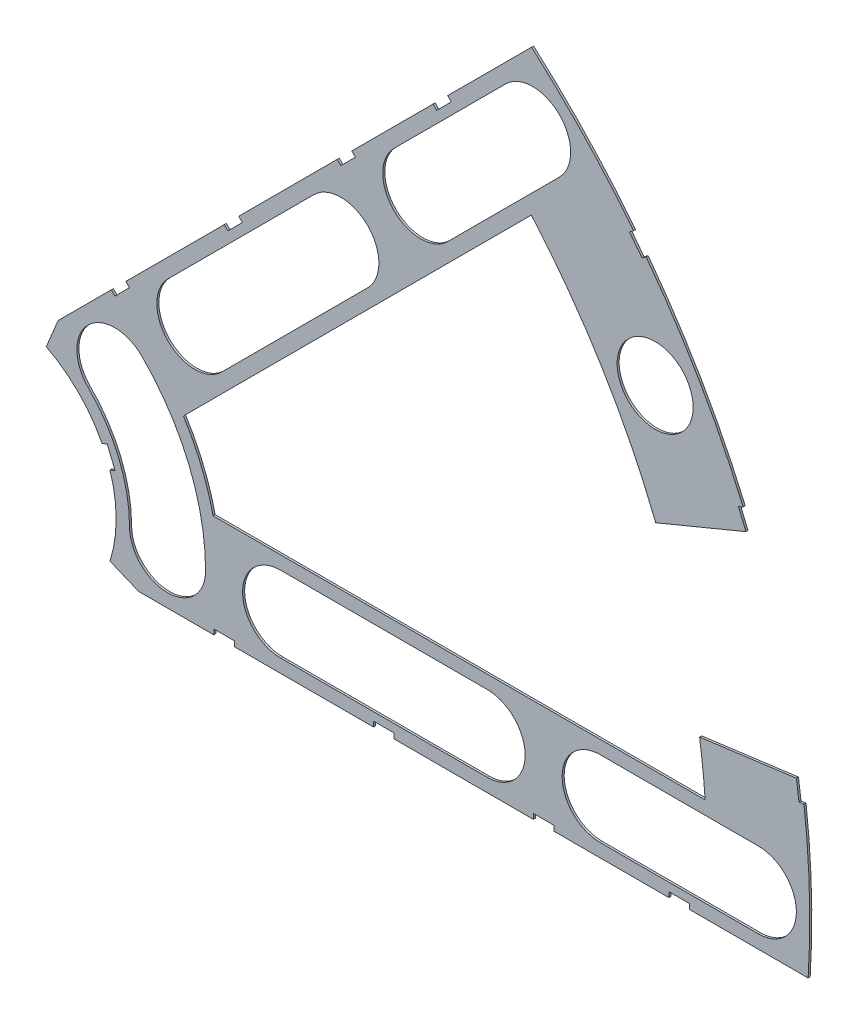
from build123d import *

# Parameters (mm, degrees)
BOSS_EXTRUDE1_DEPTH = 0.254
SKETCH2_R           = 4.699
CUT_EXTRUDE1_DEPTH  = 1.254
SKETCH3_W           = 2.54
SKETCH3_H           = 0.635
CUT_EXTRUDE2_DEPTH  = 1.254
CUT_EXTRUDE4_DEPTH  = 1.254
CUT_EXTRUDE5_DEPTH  = 1.254


with BuildPart() as part:
    # Sketch1 → Boss-Extrude1 (new body)
    with BuildSketch(Plane.XY):
        with BuildLine():
            Line((67.21146711, 76.191723231), (8.696654013, 17.676910134))
            Line((8.696654013, 17.676910134), (7.228954972, 14.133571205))
            ThreePointArc((7.228954972, 14.133571205), (14.666587579, 6.075099489), (15.105587123, -4.88230096))
            Line((15.105587123, -4.88230096), (18.648926052, -6.35))
            Line((18.648926052, -6.35), (101.401368334, -6.35))
            ThreePointArc((101.401368334, -6.35), (93.866160503, 38.880636728), (67.21146711, 76.191723231))
        make_face()
        with BuildLine():
            Line((88.672924278, 6.35), (27.86051193, 6.35))
            ThreePointArc((27.86051193, 6.35), (26.399857642, 10.93517908), (24.190484974, 15.210228852))
            Line((24.190484974, 15.210228852), (67.191354125, 58.211098004))
            ThreePointArc((67.191354125, 58.211098004), (82.13289044, 34.020557137), (88.672924278, 6.35))
        make_face(mode=Mode.SUBTRACT)
    extrude(amount=BOSS_EXTRUDE1_DEPTH)

    # Sketch2 → Cut-Extrude1 (cut, through all)
    with BuildSketch(Plane.XY.offset(0.254)):
        with Locations((22.225, 0)):
            Circle(SKETCH2_R)
        with Locations((36.195, 0)):
            Circle(SKETCH2_R)
        with Locations((61.722, 0)):
            Circle(SKETCH2_R)
        with Locations((75.692, 0)):
            Circle(SKETCH2_R)
        with Locations((95.25, 0)):
            Circle(SKETCH2_R)
        with Locations((15.715448212, 15.715448212)):
            Circle(SKETCH2_R)
        with Locations((25.593729945, 25.593729945)):
            Circle(SKETCH2_R)
        with Locations((43.644044748, 43.644044748)):
            Circle(SKETCH2_R)
        with Locations((53.522326482, 53.522326482)):
            Circle(SKETCH2_R)
        with Locations((92.004434954, 24.652514046)):
            Circle(SKETCH2_R)
        with Locations((82.48891971, 47.625)):
            Circle(SKETCH2_R)
        with Locations((67.351920908, 67.351920908)):
            Circle(SKETCH2_R)
    extrude(amount=-CUT_EXTRUDE1_DEPTH, mode=Mode.SUBTRACT)

    # Sketch3 → Cut-Extrude2 (cut, through all)
    with BuildSketch(Plane.XY.offset(0.254)):
        Polygon((15.266435406, 24.246691527), (17.06248663, 26.042742751), (17.511499436, 25.593729945), (15.715448212, 23.797678721), align=None)
        Polygon((44.991083167, 53.971339288), (43.195031942, 52.175288063), (43.644044748, 51.726275257), (45.440095973, 53.522326482), align=None)
        with Locations((29.21, -6.0325)):
            Rectangle(SKETCH3_W, SKETCH3_H)
        with Locations((68.707, -6.0325)):
            Rectangle(SKETCH3_W, SKETCH3_H)
        Polygon((29.230733674, 38.210989795), (31.026784898, 40.007041019), (31.475797704, 39.558028213), (29.67974648, 37.761976989), align=None)
        Polygon((56.845021246, 65.825277367), (55.048970022, 64.029226143), (55.497982828, 63.580213337), (57.294034052, 65.376264561), align=None)
        with Locations((48.9585, -6.0325)):
            Rectangle(SKETCH3_W, SKETCH3_H)
        with Locations((85.471, -6.0325)):
            Rectangle(SKETCH3_W, SKETCH3_H)
        Polygon((99.935462164, 14.437711971), (100.266998693, 11.919442024), (101.526133667, 12.085210288), (101.194597138, 14.603480236), align=None)
        Polygon((93.765504959, 37.464305742), (94.938831965, 37.950313702), (93.966816047, 40.296967714), (92.793489041, 39.810959755), align=None)
        Polygon((79.327792988, 62.471156422), (80.874047017, 60.456038938), (81.88160576, 61.229165953), (80.33535173, 63.244283437), align=None)
        Polygon((13.593916116, 7.005422516), (14.565932035, 4.658768503), (15.739259041, 5.144776462), (14.767243123, 7.491430475), align=None)
    extrude(amount=-CUT_EXTRUDE2_DEPTH, mode=Mode.SUBTRACT)

    # Sketch6 → Cut-Extrude4 (cut, through all)
    with BuildSketch(Plane.XY.offset(0.254)):
        with BuildLine():
            Line((22.27103518, 28.91642471), (40.321349984, 46.966739513))
            ThreePointArc((40.321349984, 46.966739513), (46.966739513, 46.966739513), (46.966739513, 40.321349984))
            Line((46.966739513, 40.321349984), (28.91642471, 22.27103518))
            ThreePointArc((28.91642471, 22.27103518), (22.27103518, 22.27103518), (22.27103518, 28.91642471))
        make_face()
        with BuildLine():
            Line((50.199631717, 56.845021246), (64.029226143, 70.674615673))
            ThreePointArc((64.029226143, 70.674615673), (70.674615673, 70.674615673), (70.674615673, 64.029226143))
            Line((70.674615673, 64.029226143), (56.845021246, 50.199631717))
            ThreePointArc((56.845021246, 50.199631717), (50.199631717, 50.199631717), (50.199631717, 56.845021246))
        make_face()
        with BuildLine():
            Line((61.722, -4.699), (36.195, -4.699))
            ThreePointArc((36.195, -4.699), (31.496, 0), (36.195, 4.699))
            Line((36.195, 4.699), (61.722, 4.699))
            ThreePointArc((61.722, 4.699), (66.421, 0), (61.722, -4.699))
        make_face()
        with BuildLine():
            Line((95.25, -4.699), (75.692, -4.699))
            ThreePointArc((75.692, -4.699), (70.993, 0), (75.692, 4.699))
            Line((75.692, 4.699), (95.25, 4.699))
            ThreePointArc((95.25, 4.699), (99.949, 0), (95.25, -4.699))
        make_face()
        with BuildLine():
            ThreePointArc((26.924, 0), (24.874532533, 10.303368733), (19.038142977, 19.038142977))
            ThreePointArc((19.038142977, 19.038142977), (12.392753447, 19.038142977), (12.392753447, 12.392753447))
            ThreePointArc((12.392753447, 12.392753447), (16.191912687, 6.706909836), (17.526, 0))
            ThreePointArc((17.526, 0), (22.225, -4.699), (26.924, 0))
        make_face()
    extrude(amount=-CUT_EXTRUDE4_DEPTH, mode=Mode.SUBTRACT)

    # Sketch5 → Cut-Extrude5 (cut, through all)
    with BuildSketch(Plane.XY.offset(0.254)):
        with BuildLine():
            Line((81.390083385, 32.475702096), (95.471027857, 38.308220267))
            ThreePointArc((95.471027857, 38.308220267), (99.36478975, 26.62471517), (101.834445583, 14.559622003))
            Line((101.834445583, 14.559622003), (86.723730875, 12.570258672))
            ThreePointArc((86.723730875, 12.570258672), (84.644080158, 22.680312922), (81.390083385, 32.475702096))
        make_face()
    extrude(amount=-CUT_EXTRUDE5_DEPTH, mode=Mode.SUBTRACT)


solid = part.part
